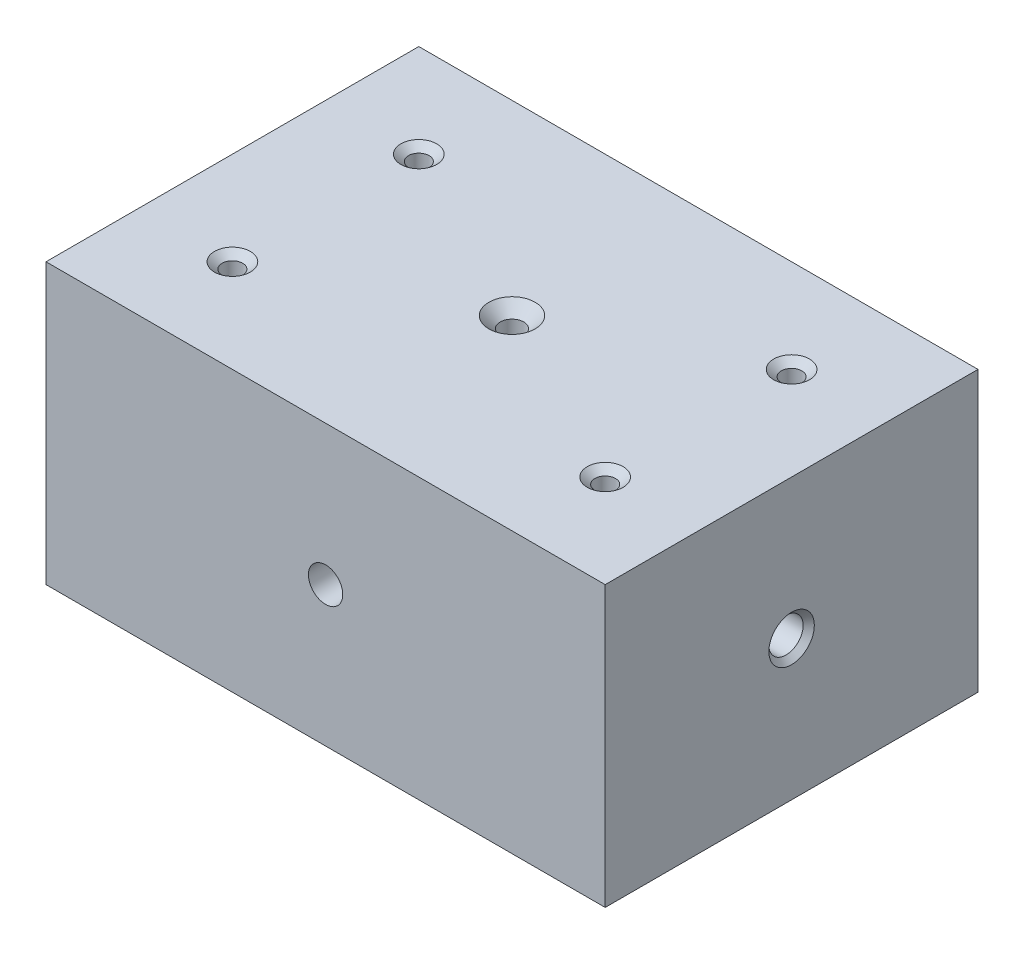
from build123d import *

# Parameters (mm, degrees)
SKETCH1_W                                          = 152.4
SKETCH1_H                                          = 101.6
BOSS_EXTRUDE1_DEPTH                                = 76.2
CSK_FOR_10_FLAT_HEAD_MACHINE_SCREW_100_D           = 5.6134
CSK_FOR_10_FLAT_HEAD_MACHINE_SCREW_100_CSINK_D     = 9.779
CSK_FOR_10_FLAT_HEAD_MACHINE_SCREW_100_CSINK_ANGLE = 100
CSK_FOR_M6_FLAT_HEAD_MACHINE_SCREW1_D              = 6.4
CSK_FOR_M6_FLAT_HEAD_MACHINE_SCREW1_CSINK_D        = 12.6
CSK_FOR_M6_FLAT_HEAD_MACHINE_SCREW1_CSINK_ANGLE    = 90
F_7_16_14_TAPPED_HOLE3_D                           = 9.3472
F_7_16_14_TAPPED_HOLE3_DEPTH                       = 20.574
F_7_16_14_TAPPED_HOLE3_CSINK_D                     = 12.3825
F_7_16_14_TAPPED_HOLE3_CSINK_ANGLE                 = 90
F_7_16_14_TAPPED_HOLE3_TIP                         = 2.808182189
F_7_16_14_TAPPED_HOLE2_D                           = 9.3472


with BuildPart() as part:
    # Sketch1 → Boss-Extrude1 (new body)
    with BuildSketch(Plane(origin=(0, 0, 0), x_dir=(1, 0, 0), z_dir=(0, 1, 0))):
        Rectangle(SKETCH1_W, SKETCH1_H)
    extrude(amount=BOSS_EXTRUDE1_DEPTH)

    # CSK for #10 Flat Head Machine Screw (100)1 (through all)
    with Locations(Plane(origin=(0, 76.2, 0), x_dir=(1, 0, 0), z_dir=(0, 1, 0))):
        with Locations((-50.8, 25.4), (-50.8, -25.4), (50.8, -25.4), (50.8, 25.4)):
            CounterSinkHole(CSK_FOR_10_FLAT_HEAD_MACHINE_SCREW_100_D / 2, CSK_FOR_10_FLAT_HEAD_MACHINE_SCREW_100_CSINK_D / 2, counter_sink_angle=CSK_FOR_10_FLAT_HEAD_MACHINE_SCREW_100_CSINK_ANGLE)

    # CSK for M6 Flat Head Machine Screw1 (through all)
    with Locations(Plane(origin=(0, 76.2, 0), x_dir=(1, 0, 0), z_dir=(0, 1, 0))):
        with Locations((0, 0)):
            CounterSinkHole(CSK_FOR_M6_FLAT_HEAD_MACHINE_SCREW1_D / 2, CSK_FOR_M6_FLAT_HEAD_MACHINE_SCREW1_CSINK_D / 2, counter_sink_angle=CSK_FOR_M6_FLAT_HEAD_MACHINE_SCREW1_CSINK_ANGLE)

    # 7/16-14 Tapped Hole3
    with Locations(Plane(origin=(76.2, 0, 0), x_dir=(0, 0, -1), z_dir=(1, 0, 0))):
        with Locations((0, 38.1)):
            CounterSinkHole(F_7_16_14_TAPPED_HOLE3_D / 2, F_7_16_14_TAPPED_HOLE3_CSINK_D / 2, depth=F_7_16_14_TAPPED_HOLE3_DEPTH, counter_sink_angle=F_7_16_14_TAPPED_HOLE3_CSINK_ANGLE)
            with Locations((0, 0, -(F_7_16_14_TAPPED_HOLE3_DEPTH + F_7_16_14_TAPPED_HOLE3_TIP / 2))):  # 118° drill point
                Cone(0, F_7_16_14_TAPPED_HOLE3_D / 2, F_7_16_14_TAPPED_HOLE3_TIP, mode=Mode.SUBTRACT)

    # 7/16-14 Tapped Hole2 (through all)
    with Locations(Plane.XY.offset(50.8)):
        with Locations((0, 38.1)):
            Hole(F_7_16_14_TAPPED_HOLE2_D / 2)


solid = part.part
